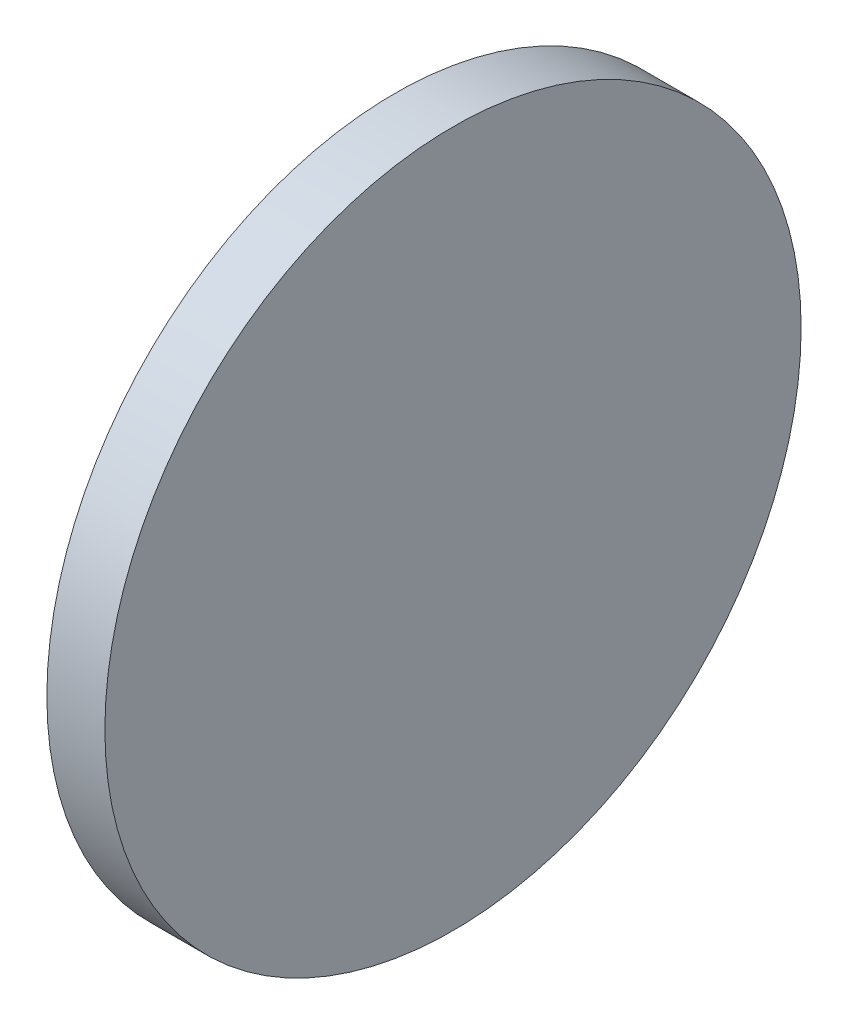
from build123d import *

# Parameters (mm, degrees)
SKETCH1_R      = 9.525
EXTRUDE1_DEPTH = 1.5875


with BuildPart() as part:
    # Sketch1 → Extrude1 (new body)
    with BuildSketch(Plane(origin=(0, 0, 0), x_dir=(0, 0, -1), z_dir=(1, 0, 0))):
        Circle(SKETCH1_R)
    extrude(amount=EXTRUDE1_DEPTH)


solid = part.part
